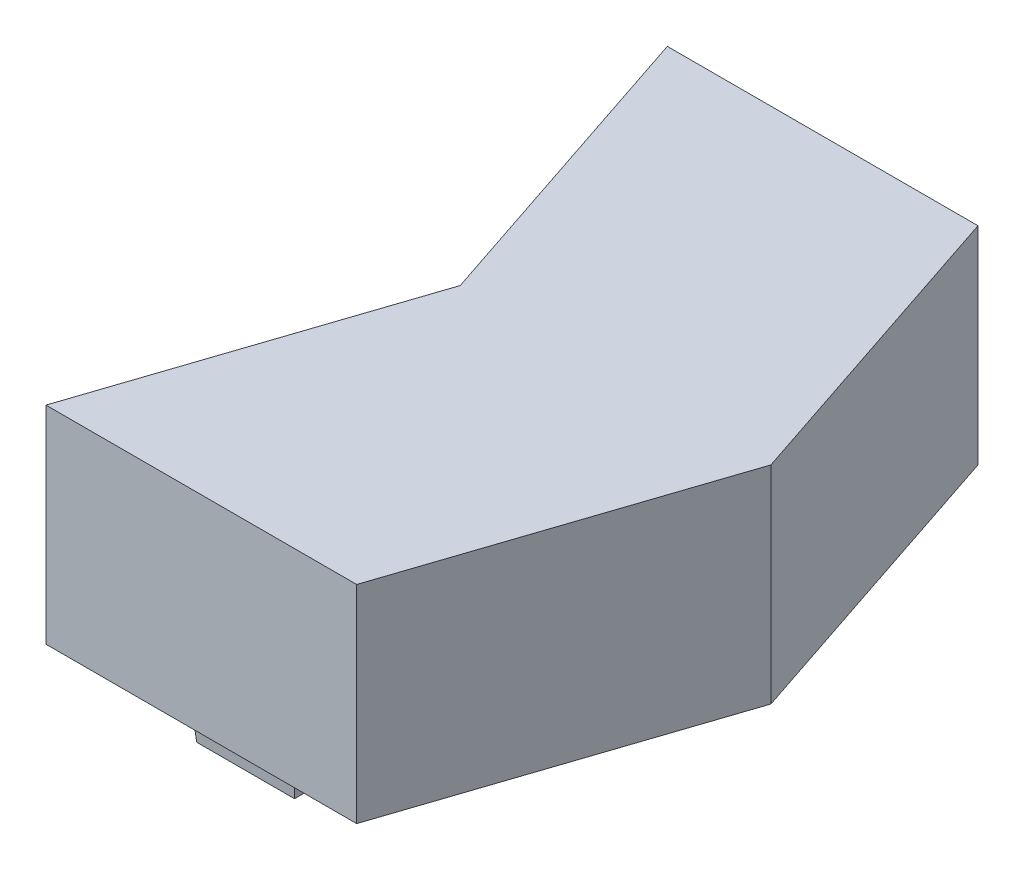
from build123d import *

# Parameters (mm, degrees)
BOSS_EXTRUDE1_DEPTH       = 12.7
SKETCH2_R                 = 5.635000033
HAPTIC_MOTOR_CUTOUT_DEPTH = 9.557999934
SKETCH3_W                 = 2.54
SKETCH3_H                 = 3.81
HAPTIC_WIRE_CUTOUT_DEPTH  = 9.557999934
SKETCH4_W                 = 6.35
SKETCH4_H                 = 2.54
PINS_DEPTH                = 2.032
PINS_TAPER                = 5


with BuildPart() as part:
    # Sketch1 → Boss-Extrude1 (new body)
    with BuildSketch(Plane(origin=(0, 0, 0), x_dir=(1, 0, 0), z_dir=(0, 1, 0))):
        Polygon((0, 0), (19.05, 0), (25.4, 19.05), (19.05, 38.1), (0, 38.1), (6.35, 19.05), align=None)
    extrude(amount=BOSS_EXTRUDE1_DEPTH)

    # Sketch2 → Haptic Motor Cutout (cut)
    with BuildSketch(Plane.XZ):
        with Locations((15.24, -19.05)):
            Circle(SKETCH2_R)
    extrude(amount=-HAPTIC_MOTOR_CUTOUT_DEPTH, mode=Mode.SUBTRACT)

    # Sketch3 → Haptic Wire Cutout (cut)
    with BuildSketch(Plane.XZ):
        with Locations((15.24, -26.445020526)):
            Rectangle(SKETCH3_W, SKETCH3_H)
    extrude(amount=-HAPTIC_WIRE_CUTOUT_DEPTH, mode=Mode.SUBTRACT)

    # Sketch4 → Pins (add)
    with BuildSketch(Plane.XZ):
        with Locations((10.795, -35.56)):
            Rectangle(SKETCH4_W, SKETCH4_H)
    pins = extrude(amount=PINS_DEPTH, taper=PINS_TAPER)

    # Mirror1: Pins across plane
    add(pins.mirror(Plane(origin=(0, 0, -19.05), x_dir=(1, 0, 0), z_dir=(0, 0, -1))))


solid = part.part
